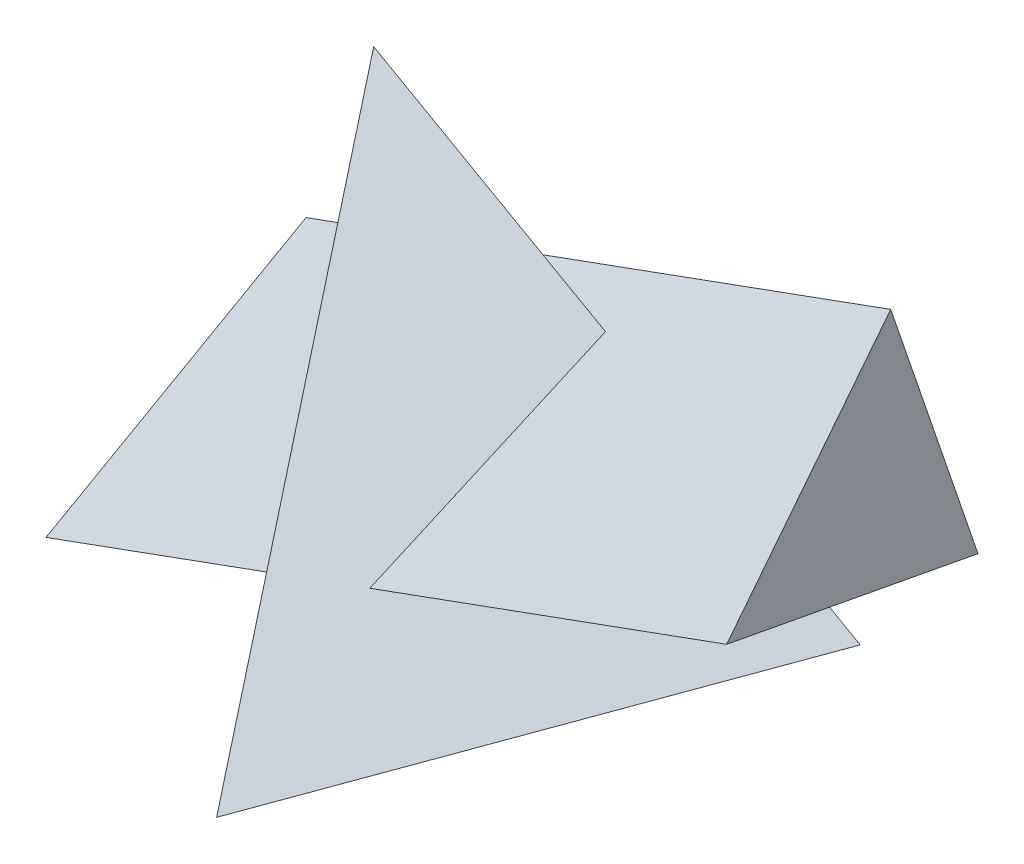
from build123d import *

# Parameters (mm, degrees)
CUT_ON_LHS_OF_PRISM_DEPTH = 91.0000001


with BuildPart() as part:
    # point → Pyramid section 0
    with BuildSketch(Plane(origin=(18.75, -32.475952642, 0), x_dir=(-0.866025404, -0.5, 0), z_dir=(0.5, -0.866025404, 0)), mode=Mode.PRIVATE) as pyramid_s0:
        Polygon((-184.951905284, -30), (-64.951905284, 30), (-64.951905284, -90), align=None)
    loft([pyramid_s0.sketch, Vertex(55, 130, 30)])

    # Triangular prism: sweep along a path in Sketch11
    with BuildLine(Plane.XY) as triangular_prism_path:
        Line((0, 0), (178.923048454, 65.122663861))
    # Sketch10 → Triangular prism (sweep)
    with BuildSketch(Plane(origin=(178.923048454, 0, 0), x_dir=(0, 0, -1), z_dir=(1, 0, 0))):
        Polygon((0, 65.122663861), (-22.231309316, 130.122663861), (-64.012503946, 77.13417837), align=None)
    sweep(path=triangular_prism_path.line)

    # Sketch8 → Cut on LHS of prism (cut, through all)
    with BuildSketch(Plane.XY):
        Polygon((0, 0), (30, 75.919107028), (0, 75.919107028), align=None)
    extrude(amount=CUT_ON_LHS_OF_PRISM_DEPTH, mode=Mode.SUBTRACT)


solid = part.part
